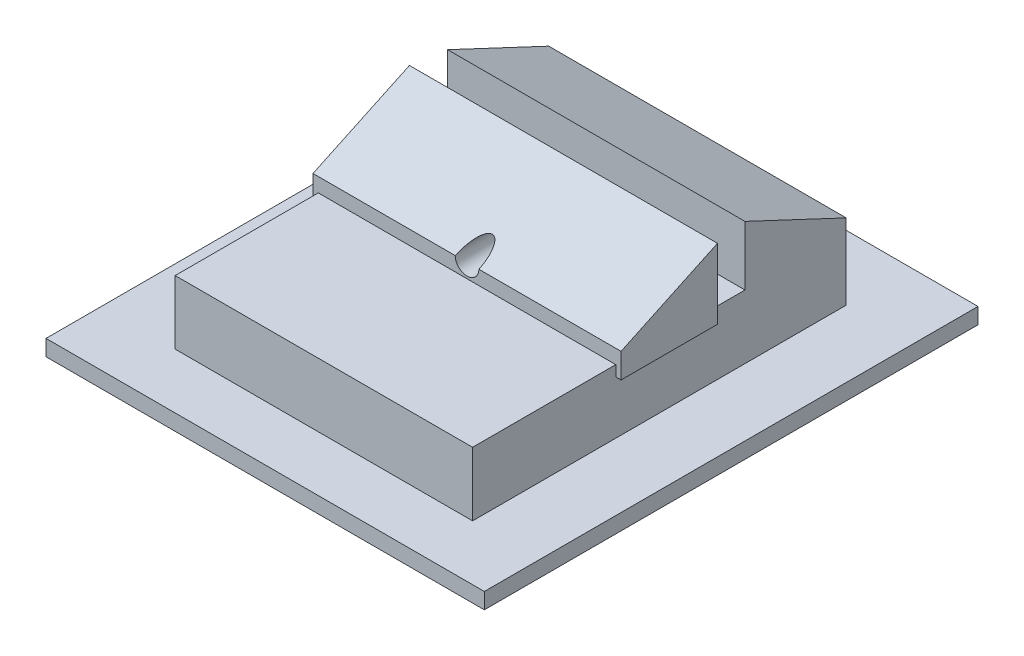
from build123d import *

# Parameters (mm, degrees)
SKETCH1_W            = 35.169359311
SKETCH1_H            = 6
BOSS_EXTRUDE1_DEPTH  = 25
SKETCH2_W            = 35.169359311
SKETCH2_H            = 6
BOSS_EXTRUDE2_DEPTH  = 1.5
SKETCH3_W            = 35.169359311
SKETCH3_H            = 6
BOSS_EXTRUDE3_DEPTH  = 1.5
SKETCH4_W            = 41.262531498
SKETCH4_H            = 46.473158343
BOSS_EXTRUDE4_DEPTH  = 1.5
BOSS_EXTRUDE5_DEPTH  = 2
BOSS_EXTRUDE6_DEPTH  = 2
SKETCH8_W            = 9.078602689
SKETCH8_H            = 1
BOSS_EXTRUDE7_DEPTH  = 0.5
SKETCH9_W            = 9.078602689
SKETCH9_H            = 1
BOSS_EXTRUDE8_DEPTH  = 0.5
BOSS_EXTRUDE9_DEPTH  = 1.5
BOSS_EXTRUDE10_DEPTH = 1.5
SKETCH13_R           = 1.114440401
CUT_EXTRUDE1_DEPTH   = 10


with BuildPart() as part:
    # Sketch1 → Boss-Extrude1 (new body)
    with BuildSketch(Plane(origin=(0, 0, 0), x_dir=(0, 0, -1), z_dir=(1, 0, 0))):
        Polygon((-55.278617962, 72.850669778), (-46.200015273, 72.850669778), (-46.200015273, 78.4511375), (-55.278617962, 74.184840555), align=None)
        with Locations((-51.170377926, 69.850669778)):
            Rectangle(SKETCH1_W, SKETCH1_H)
        Polygon((-43.112055174, 72.850669778), (-33.58569827, 72.850669778), (-33.58569827, 73.967743314), (-43.112055174, 78.444452863), align=None)
    extrude(amount=BOSS_EXTRUDE1_DEPTH)

    # Sketch2 → Boss-Extrude2 (add)
    with BuildSketch(Plane(origin=(25, 0, 0), x_dir=(0, 0, -1), z_dir=(1, 0, 0))):
        with Locations((-51.170377926, 69.850669778)):
            Rectangle(SKETCH2_W, SKETCH2_H)
    extrude(amount=BOSS_EXTRUDE2_DEPTH)

    # Sketch3 → Boss-Extrude3 (add)
    with BuildSketch(Plane.ZY):
        with Locations((51.170377926, 69.850669778)):
            Rectangle(SKETCH3_W, SKETCH3_H)
    extrude(amount=BOSS_EXTRUDE3_DEPTH)

    # Sketch4 → Boss-Extrude4 (add)
    with BuildSketch(Plane.XZ.offset(-66.850669778)):
        with Locations((12.174758659, 50.720136909)):
            Rectangle(SKETCH4_W, SKETCH4_H)
    extrude(amount=BOSS_EXTRUDE4_DEPTH)

    # Sketch6 → Boss-Extrude5 (add)
    with BuildSketch(Plane(origin=(25, 0, 0), x_dir=(0, 0, -1), z_dir=(1, 0, 0))):
        Polygon((-55.278617962, 72.850669778), (-55.278617962, 74.184840555), (-46.200015273, 78.4511375), (-46.200015273, 72.850669778), align=None)
    extrude(amount=BOSS_EXTRUDE5_DEPTH)

    # Sketch7 → Boss-Extrude6 (add)
    with BuildSketch(Plane.ZY):
        Polygon((46.200015273, 72.850669778), (55.278617962, 72.850669778), (55.278617962, 74.184840555), (46.200015273, 78.4511375), align=None)
    extrude(amount=BOSS_EXTRUDE6_DEPTH)

    # Sketch8 → Boss-Extrude7 (add)
    with BuildSketch(Plane(origin=(26.5, 0, 0), x_dir=(0, 0, -1), z_dir=(1, 0, 0))):
        with Locations((-50.739316618, 72.350669778)):
            Rectangle(SKETCH8_W, SKETCH8_H)
    extrude(amount=BOSS_EXTRUDE7_DEPTH)

    # Sketch9 → Boss-Extrude8 (add)
    with BuildSketch(Plane.ZY.offset(1.5)):
        with Locations((50.739316618, 72.350669778)):
            Rectangle(SKETCH9_W, SKETCH9_H)
    extrude(amount=BOSS_EXTRUDE8_DEPTH)

    # Sketch10 → Boss-Extrude9 (add)
    with BuildSketch(Plane(origin=(25, 0, 0), x_dir=(0, 0, -1), z_dir=(1, 0, 0))):
        Polygon((-43.112055174, 72.850669778), (-33.58569827, 72.850669778), (-33.58569827, 73.967743314), (-43.112055174, 78.444452863), align=None)
    extrude(amount=BOSS_EXTRUDE9_DEPTH)

    # Sketch11 → Boss-Extrude10 (add)
    with BuildSketch(Plane.ZY):
        Polygon((33.58569827, 72.850669778), (43.112055174, 72.850669778), (43.112055174, 78.444452863), (33.58569827, 73.967743314), align=None)
    extrude(amount=BOSS_EXTRUDE10_DEPTH)

    # Sketch13 → Cut-Extrude1 (cut)
    with BuildSketch(Plane.XY.offset(55.278617962)):
        with Locations((12.5, 74.184840555)):
            Circle(SKETCH13_R)
    extrude(amount=-CUT_EXTRUDE1_DEPTH, mode=Mode.SUBTRACT)


solid = part.part
